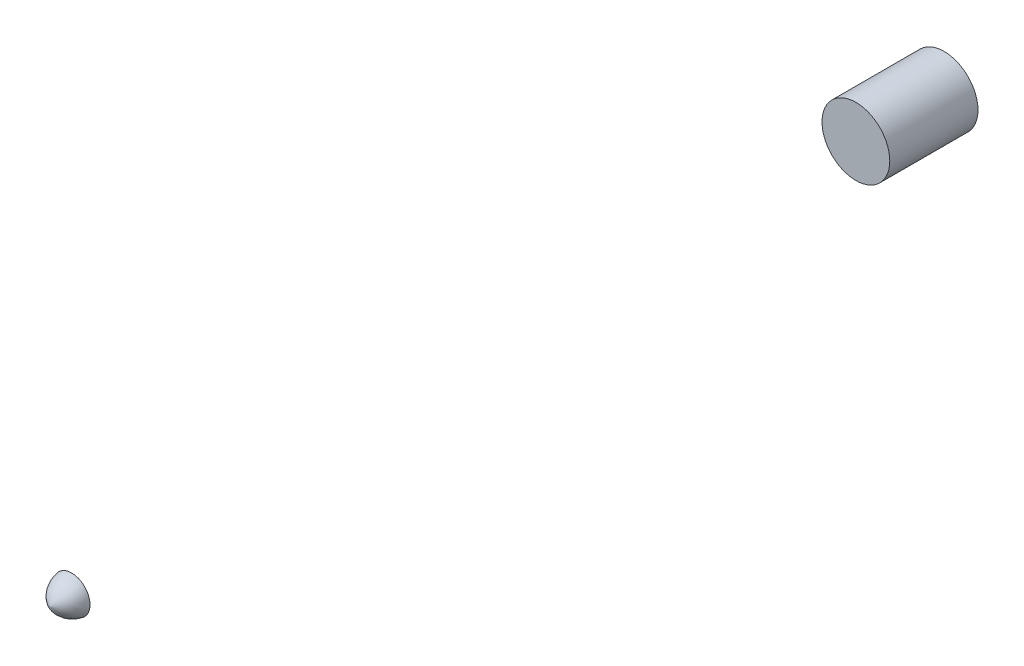
from build123d import *

# Parameters (mm, degrees)
SKETCH_1_R      = 4.8
EXTRUDE_1_DEPTH = 12.5


with BuildPart() as part:
    # 草圖1 → 填料-伸長1 (new body)
    with BuildSketch(Plane.XY):
        Circle(SKETCH_1_R)
    extrude(amount=EXTRUDE_1_DEPTH)


with BuildPart() as body_2:
    # 草圖6 → 旋轉3 (revolve)
    with BuildSketch(Plane(origin=(0, 0, 0), x_dir=(1, 0, 0), z_dir=(0, 1, 0))):
        with BuildLine():
            Line((0, -126.6), (0, -123.6))
            Line((0, -123.6), (-2.6, -123.6))
            ThreePointArc((-2.6, -123.6), (-1.742605658, -125.48359157), (0, -126.6))
        make_face()
    revolve(axis=Axis((0, 0, 123.6), (0, 0, 1)))


solid = Compound([part.part, body_2.part])
